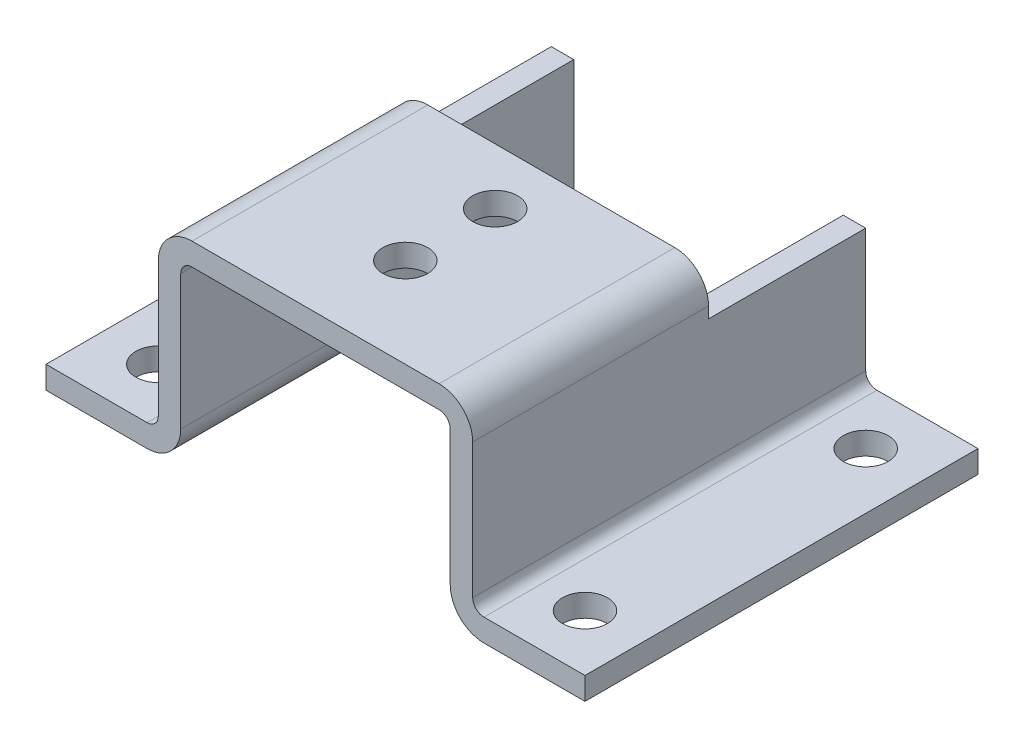
from build123d import *

# Parameters (mm, degrees)
EXTRUDE_1_DEPTH     = 35
SKETCH_2_W          = 48
SKETCH_2_H          = 14
CUT_EXTRUDE_1_DEPTH = 4
SKETCH_3_R          = 2
CUT_EXTRUDE_2_DEPTH = 19


with BuildPart() as part:
    # Эскиз1 → Бобышка-Вытянуть1 (new body)
    with BuildSketch(Plane.XY):
        with BuildLine():
            Line((0, 0), (9, 0))
            ThreePointArc((9, 0), (11.121320344, 0.878679656), (12, 3))
            Line((12, 3), (12, 15))
            ThreePointArc((12, 15), (12.292893219, 15.707106781), (13, 16))
            Line((13, 16), (35, 16))
            ThreePointArc((35, 16), (35.707106781, 15.707106781), (36, 15))
            Line((36, 15), (36, 3))
            ThreePointArc((36, 3), (36.878679656, 0.878679656), (39, 0))
            Line((39, 0), (48, 0))
            Line((48, 0), (48, 2))
            Line((48, 2), (39, 2))
            ThreePointArc((39, 2), (38.292893219, 2.292893219), (38, 3))
            Line((38, 3), (38, 15))
            ThreePointArc((38, 15), (37.121320344, 17.121320344), (35, 18))
            Line((35, 18), (13, 18))
            ThreePointArc((13, 18), (10.878679656, 17.121320344), (10, 15))
            Line((10, 15), (10, 3))
            ThreePointArc((10, 3), (9.707106781, 2.292893219), (9, 2))
            Line((9, 2), (0, 2))
            Line((0, 2), (0, 0))
        make_face()
    extrude(amount=EXTRUDE_1_DEPTH)

    # Эскиз2 → Вырез-Вытянуть1 (cut)
    with BuildSketch(Plane(origin=(0, 18, 0), x_dir=(1, 0, 0), z_dir=(0, 1, 0))):
        with Locations((24, -7)):
            Rectangle(SKETCH_2_W, SKETCH_2_H)
    extrude(amount=-CUT_EXTRUDE_1_DEPTH, mode=Mode.SUBTRACT)

    # Эскиз3 → Вырез-Вытянуть2 (cut, through all)
    with BuildSketch(Plane(origin=(0, 18, 0), x_dir=(1, 0, 0), z_dir=(0, 1, 0))):
        with Locations((24, -19)):
            Circle(SKETCH_3_R)
        with Locations((24, -27)):
            Circle(SKETCH_3_R)
        with Locations((5, -30)):
            Circle(SKETCH_3_R)
        with Locations((5, -5)):
            Circle(SKETCH_3_R)
        with Locations((43, -30)):
            Circle(SKETCH_3_R)
        with Locations((43, -5)):
            Circle(SKETCH_3_R)
    extrude(amount=-CUT_EXTRUDE_2_DEPTH, mode=Mode.SUBTRACT)


solid = part.part
